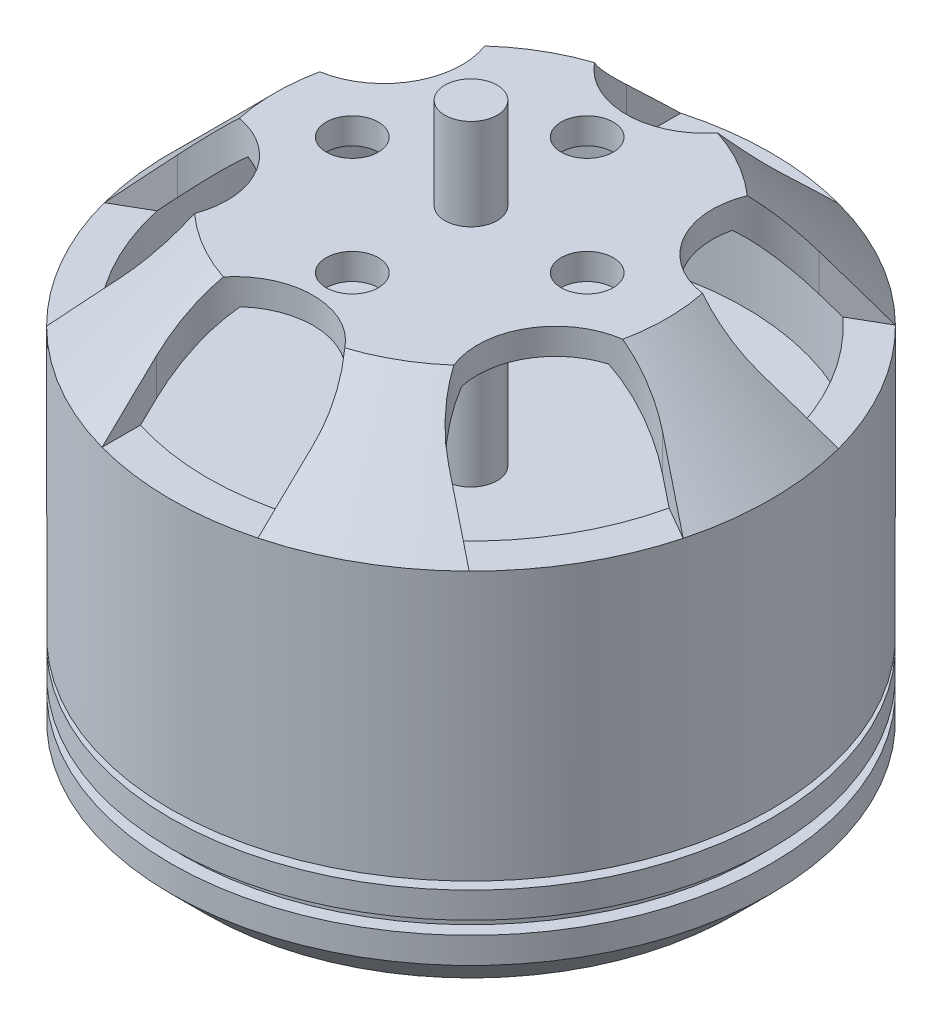
from build123d import *

# Parameters (mm, degrees)
SKETCH2_R          = 1
CUT_EXTRUDE1_DEPTH = 4
SKETCH3_R          = 1
CUT_EXTRUDE2_DEPTH = 3


with BuildPart() as part:
    # Sketch1 → Revolve1 (revolve)
    with BuildSketch(Plane.XY):
        Polygon((0.048979582, -2.362225903), (1.048979582, -2.362225903), (1.048979582, -0.562225903), (10.134766019, -0.562225903), (11.548979582, 0.85198766), (11.548979582, 1.85198766), (11.048979582, 1.85198766), (11.048979582, 2.35198766), (11.548979582, 2.35198766), (11.548979582, 3.35198766), (9.548979582, 3.35198766), (9.548979582, 3.65198766), (11.548979582, 3.65198766), (11.548979582, 13.937774097), (7.548979582, 17.937774097), (1.048979582, 17.937774097), (1.048979582, 21.437774097), (0.048979582, 21.437774097), align=None)
        Polygon((2.048979582, 16.937774097), (7.134766019, 16.937774097), (10.548979582, 13.523560535), (10.548979582, 9.305259573), (1.048979582, 9.305259573), (1.048979582, 15.937774097), (2.048979582, 15.937774097), align=None, mode=Mode.SUBTRACT)
    revolve(axis=Axis((0.048979582, 21.437774097, 0), (0, -1, 0)))

    # Sketch2 → Cut-Extrude1 (cut)
    with BuildSketch(Plane(origin=(0, 17.937774097, 0), x_dir=(1, 0, 0), z_dir=(0, 1, 0))):
        with Locations((0, 4.5)):
            Circle(SKETCH2_R)
        with Locations((4.5, 0)):
            Circle(SKETCH2_R)
        with Locations((0, -4.5)):
            Circle(SKETCH2_R)
        with Locations((-4.5, 0)):
            Circle(SKETCH2_R)
        with BuildLine():
            Line((-3, 9), (-3, 17.185640614))
            Line((-3, 17.185640614), (3, 17.185640614))
            Line((3, 17.185640614), (3, 9))
            ThreePointArc((3, 9), (0, 6), (-3, 9))
        make_face()
        with BuildLine():
            Line((16.383201352, 5.994744096), (9.294228634, 1.901923789))
            ThreePointArc((9.294228634, 1.901923789), (5.196152423, 3), (6.294228634, 7.098076211))
            Line((6.294228634, 7.098076211), (13.383201352, 11.190896518))
            Line((13.383201352, 11.190896518), (16.383201352, 5.994744096))
        make_face()
        with BuildLine():
            Line((13.383201352, -11.190896518), (6.294228634, -7.098076211))
            ThreePointArc((6.294228634, -7.098076211), (5.196152423, -3), (9.294228634, -1.901923789))
            Line((9.294228634, -1.901923789), (16.383201352, -5.994744096))
            Line((16.383201352, -5.994744096), (13.383201352, -11.190896518))
        make_face()
        with BuildLine():
            Line((-3, -17.185640614), (-3, -9))
            ThreePointArc((-3, -9), (0, -6), (3, -9))
            Line((3, -9), (3, -17.185640614))
            Line((3, -17.185640614), (-3, -17.185640614))
        make_face()
        with BuildLine():
            Line((-16.383201352, -5.994744096), (-9.294228634, -1.901923789))
            ThreePointArc((-9.294228634, -1.901923789), (-5.196152423, -3), (-6.294228634, -7.098076211))
            Line((-6.294228634, -7.098076211), (-13.383201352, -11.190896518))
            Line((-13.383201352, -11.190896518), (-16.383201352, -5.994744096))
        make_face()
        with BuildLine():
            Line((-13.383201352, 11.190896518), (-6.294228634, 7.098076211))
            ThreePointArc((-6.294228634, 7.098076211), (-5.196152423, 3), (-9.294228634, 1.901923789))
            Line((-9.294228634, 1.901923789), (-16.383201352, 5.994744096))
            Line((-16.383201352, 5.994744096), (-13.383201352, 11.190896518))
        make_face()
    extrude(amount=-CUT_EXTRUDE1_DEPTH, mode=Mode.SUBTRACT)

    # Sketch3 → Cut-Extrude2 (cut)
    with BuildSketch(Plane.XZ.offset(0.562225903)):
        with Locations((0, 6)):
            Circle(SKETCH3_R)
        with Locations((6, 0)):
            Circle(SKETCH3_R)
        with Locations((0, -6)):
            Circle(SKETCH3_R)
        with Locations((-6, 0)):
            Circle(SKETCH3_R)
    extrude(amount=-CUT_EXTRUDE2_DEPTH, mode=Mode.SUBTRACT)


solid = part.part
